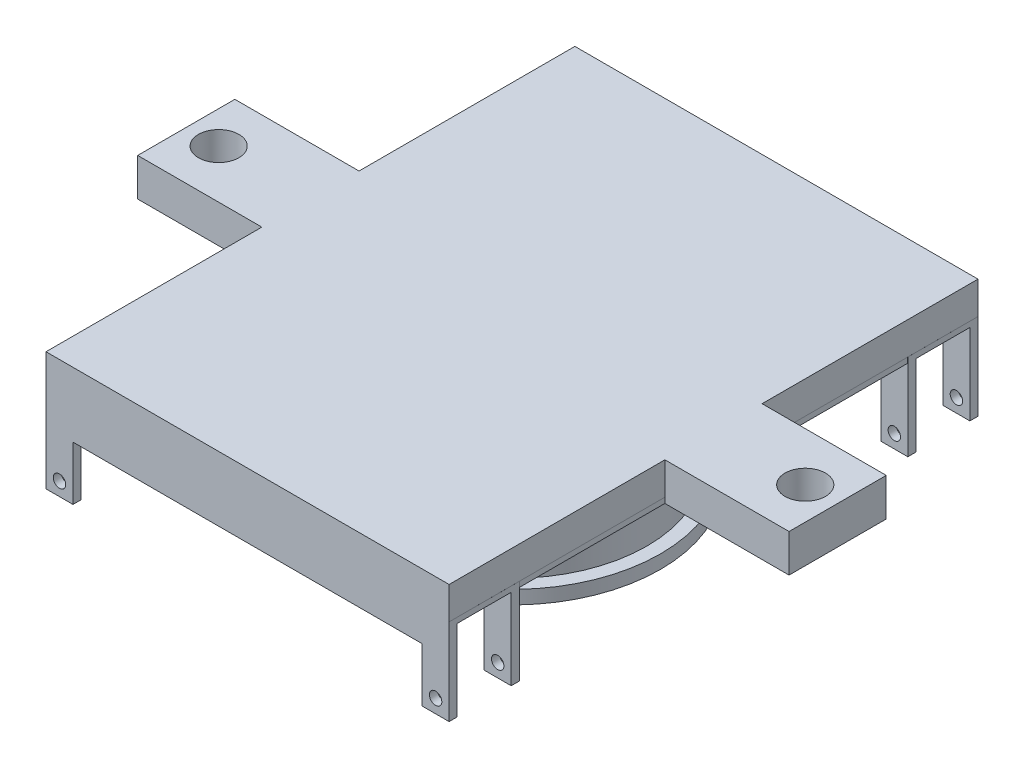
from build123d import *

# Parameters (mm, degrees)
SKETCH2_W               = 5
SKETCH2_H               = 74.664160083
SKETCH2_W_2             = 10
SKETCH2_H_2             = 5
SKETCH2_R               = 1.15
BOSS_EXTRUDE1_DEPTH     = 1.5
SKETCH3_W               = 13
SKETCH3_H               = 74.664160083
BOSS_EXTRUDE2_DEPTH     = 1
SKETCH5_W               = 97.96
SKETCH5_H               = 74.648794292
BOSS_EXTRUDE3_DEPTH     = 1
SKETCH6_R               = 25
SKETCH6_R_2             = 23
BOSS_EXTRUDE4_DEPTH     = 17.5
SKETCH8_R               = 27.5
SKETCH8_R_2             = 23.5
BOSS_EXTRUDE6_DEPTH     = 2.5
SKETCH13_W              = 18
SKETCH13_H              = 23
BOSS_EXTRUDE7_DEPTH     = 1
SKETCH15_R              = 3.75
CUT_EXTRUDE3_DEPTH      = 1
BODY_MOVE_COPY2_ANGLE   = 90
SKETCH16_R              = 3.75
BOSS_EXTRUDE8_DEPTH     = 6
SKETCH17_R              = 0.9
CUT_EXTRUDE4_DEPTH      = 46
CUT_EXTRUDE4_DEPTH_BACK = 44


with BuildPart() as part:
    # Sketch2 → Boss-Extrude1 (new body)
    with BuildSketch(Plane.XY):
        with Locations((376.369557123, 140.674264472)):
            Rectangle(SKETCH2_W, SKETCH2_H)
        with Locations((368.869557123, 175.506344513)):
            Rectangle(SKETCH2_W_2, SKETCH2_H_2)
        with Locations((366.369557123, 175.506344513)):
            Circle(SKETCH2_R, mode=Mode.SUBTRACT)
        with Locations((368.869557123, 105.84218443)):
            Rectangle(SKETCH2_W_2, SKETCH2_H_2)
        with Locations((366.369557123, 105.84218443)):
            Circle(SKETCH2_R, mode=Mode.SUBTRACT)
    boss_extrude1 = extrude(amount=BOSS_EXTRUDE1_DEPTH)

    # Sketch3 → Boss-Extrude2 (add)
    with BuildSketch(Plane(origin=(378.869557123, 0, 0), x_dir=(0, 0, -1), z_dir=(1, 0, 0))):
        with Locations((5, 140.674264472)):
            Rectangle(SKETCH3_W, SKETCH3_H)
    extrude(amount=BOSS_EXTRUDE2_DEPTH)

    # Mirror3: Boss-Extrude1 across plane
    add(boss_extrude1.mirror(Plane(origin=(0, 0, -5), x_dir=(1, 0, 0), z_dir=(0, 0, -1))))


with BuildPart() as body_2:
    # Body-Move/Copy1: copy of part
    add(part.part.moved(Location((0, 0, 84.96))))


with BuildPart() as part_1:
    add(part.part)

    add(body_2.part)  # Boss-Extrude3 merges body 2
    # Sketch5 → Boss-Extrude3 (add)
    with BuildSketch(Plane(origin=(379.869557123, 0, 0), x_dir=(0, 0, -1), z_dir=(1, 0, 0))):
        with Locations((-37.48, 140.681947367)):
            Rectangle(SKETCH5_W, SKETCH5_H)
    extrude(amount=-BOSS_EXTRUDE3_DEPTH)

    # Sketch6 → Boss-Extrude4 (add)
    with BuildSketch(Plane.ZY.offset(-378.869557123)):
        with Locations(Location((37.48, 140.674264472, 0), (0, 0, 270))):
            Circle(SKETCH6_R)
        with Locations(Location((37.48, 140.674264472, 0), (0, 0, 270))):
            Circle(SKETCH6_R_2, mode=Mode.SUBTRACT)
    extrude(amount=BOSS_EXTRUDE4_DEPTH)

    # Sketch8 → Boss-Extrude6 (add)
    with BuildSketch(Plane.ZY.offset(-361.369557123)):
        with Locations(Location((37.48, 140.674264472, 0), (0, 0, 270))):
            Circle(SKETCH8_R)
        with Locations(Location((37.48, 140.674264472, 0), (0, 0, 270))):
            Circle(SKETCH8_R_2, mode=Mode.SUBTRACT)
    extrude(amount=BOSS_EXTRUDE6_DEPTH)

    # Sketch13 → Boss-Extrude7 (add)
    with BuildSketch(Plane.ZY.offset(-378.869557123)):
        with Locations((37.48, 189.506344513)):
            Rectangle(SKETCH13_W, SKETCH13_H)
        with Locations((37.48, 91.857550221)):
            Rectangle(SKETCH13_W, SKETCH13_H)
    extrude(amount=-BOSS_EXTRUDE7_DEPTH)

    # Sketch15 → Cut-Extrude3 (cut)
    with BuildSketch(Plane.ZY.offset(-378.869557123)):
        with Locations(Location((37.48, 195.006344513, 0), (0, 0, 270))):
            Circle(SKETCH15_R)
        with Locations(Location((37.48, 86.357550221, 0), (0, 0, 270))):
            Circle(SKETCH15_R)
    extrude(amount=-CUT_EXTRUDE3_DEPTH, mode=Mode.SUBTRACT)


with BuildPart() as part_2:
    # Body-Move/Copy2: moved
    add(part_1.part.rotate(Axis((371.869557123, 140.681947367, 0), (0, 0, 1)), BODY_MOVE_COPY2_ANGLE))

    # Sketch16 → Boss-Extrude8 (add)
    with BuildSketch(Plane(origin=(0, 148.681947367, 0), x_dir=(1, 0, 0), z_dir=(0, 1, 0))):
        Polygon((334.545159977, -28.48), (334.545159977, 11.5), (409.20932006, 11.5), (409.193954269, -28.48), (432.193954269, -28.48), (432.193954269, -46.48), (409.193954269, -46.48), (409.20932006, -86.46), (334.545159977, -86.46), (334.545159977, -46.48), (311.545159977, -46.48), (311.545159977, -28.48), align=None)
        with Locations((317.545159977, -37.48)):
            Circle(SKETCH16_R, mode=Mode.SUBTRACT)
        with Locations((426.193954269, -37.48)):
            Circle(SKETCH16_R, mode=Mode.SUBTRACT)
    extrude(amount=BOSS_EXTRUDE8_DEPTH)

    # Sketch17 → Cut-Extrude4 (cut, two sides)
    with BuildSketch(Plane.XY.offset(37.48)) as cut_extrude4_sk:
        with Locations(Location((371.877240018, 135.681947367, 0), (0, 0, 180))):
            Circle(SKETCH17_R)
    extrude(amount=CUT_EXTRUDE4_DEPTH, mode=Mode.SUBTRACT)
    extrude(cut_extrude4_sk.sketch, amount=-CUT_EXTRUDE4_DEPTH_BACK, mode=Mode.SUBTRACT)


solid = part_2.part
